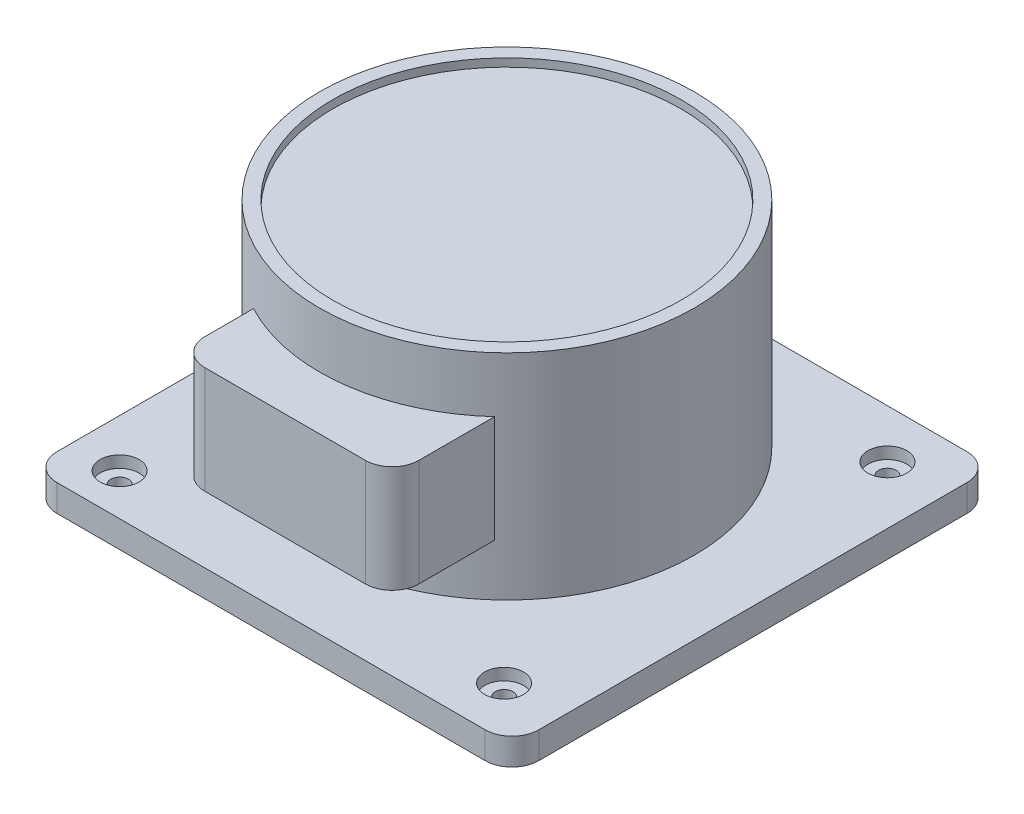
from build123d import *

# Parameters (mm, degrees)
SKETCH1_W                               = 180
SKETCH1_H                               = 180
BOSS_EXTRUDE1_DEPTH                     = 10
SKETCH2_R                               = 70
BOSS_EXTRUDE2_DEPTH                     = 80
SKETCH3_W                               = 80
SKETCH3_H                               = 40
BOSS_EXTRUDE3_DEPTH                     = 90
SKETCH4_R                               = 65
CUT_EXTRUDE1_DEPTH                      = 3
CBORE_FOR_M6_HEX_HEAD_BOLT1_D           = 6.6
CBORE_FOR_M6_HEX_HEAD_BOLT1_CBORE_D     = 14.55
CBORE_FOR_M6_HEX_HEAD_BOLT1_CBORE_DEPTH = 4.38
FILLET1_R                               = 10


with BuildPart() as part:
    # Sketch1 → Boss-Extrude1 (new body)
    with BuildSketch(Plane(origin=(0, 0, 0), x_dir=(1, 0, 0), z_dir=(0, 1, 0))):
        with Locations((-49.591836735, -5.510204082)):
            Rectangle(SKETCH1_W, SKETCH1_H)
    extrude(amount=BOSS_EXTRUDE1_DEPTH)

    # Sketch2 → Boss-Extrude2 (add)
    with BuildSketch(Plane(origin=(0, 10, 0), x_dir=(1, 0, 0), z_dir=(0, 1, 0))):
        with Locations((-57.006666854, 0)):
            Circle(SKETCH2_R)
    extrude(amount=BOSS_EXTRUDE2_DEPTH)

    # Sketch3 → Boss-Extrude3 (add)
    with BuildSketch(Plane.XY):
        with Locations((-49.893940427, 49.288531055)):
            Rectangle(SKETCH3_W, SKETCH3_H)
    extrude(amount=BOSS_EXTRUDE3_DEPTH)

    # Sketch4 → Cut-Extrude1 (cut)
    with BuildSketch(Plane(origin=(0, 90, 0), x_dir=(1, 0, 0), z_dir=(0, 1, 0))):
        with Locations((-57.006666854, 0)):
            Circle(SKETCH4_R)
    extrude(amount=-CUT_EXTRUDE1_DEPTH, mode=Mode.SUBTRACT)

    # CBORE for M6 Hex Head Bolt1 (through all)
    with Locations(Plane(origin=(0, 10, 0), x_dir=(1, 0, 0), z_dir=(0, 1, 0))):
        with Locations((-121.727687168, 66.314718067), (18.854420034, 66.314718067), (18.854420034, -76.9115667), (-121.727687168, -79.996440525)):
            CounterBoreHole(CBORE_FOR_M6_HEX_HEAD_BOLT1_D / 2, CBORE_FOR_M6_HEX_HEAD_BOLT1_CBORE_D / 2, CBORE_FOR_M6_HEX_HEAD_BOLT1_CBORE_DEPTH)

    # Fillet1
    fillet1_edges = [part.edges().sort_by_distance(p)[0] for p in [
        (-89.893940427, 49.288531055, 90),
        (-9.893940427, 49.288531055, 90),
        (-139.591836735, 5, -84.489795918),
        (40.408163265, 5, -84.489795918),
        (40.408163265, 5, 95.510204082),
        (-139.591836735, 5, 95.510204082),
    ]]
    fillet(fillet1_edges, radius=FILLET1_R)


solid = part.part
